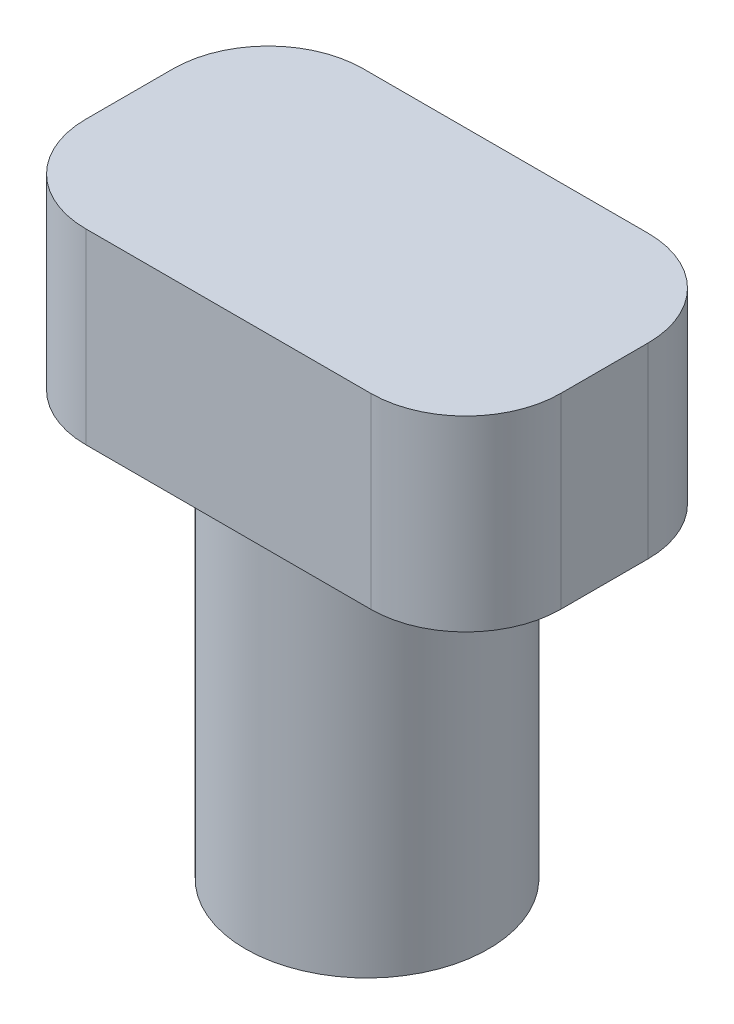
from build123d import *

# Parameters (mm, degrees)
SKETCH1_R           = 3.25
BOSS_EXTRUDE1_DEPTH = 10
SKETCH2_R           = 1.75
CUT_EXTRUDE1_DEPTH  = 2.5
SKETCH3_W           = 12.7
SKETCH3_H           = 7.4168
BOSS_EXTRUDE2_DEPTH = 5
FILLET1_R           = 2.54


with BuildPart() as part:
    # Sketch1 → Boss-Extrude1 (new body)
    with BuildSketch(Plane(origin=(0, 0, 0), x_dir=(1, 0, 0), z_dir=(0, 1, 0))):
        Circle(SKETCH1_R)
    extrude(amount=BOSS_EXTRUDE1_DEPTH)

    # Sketch2 → Cut-Extrude1 (cut)
    with BuildSketch(Plane.XZ):
        Circle(SKETCH2_R)
    extrude(amount=-CUT_EXTRUDE1_DEPTH, mode=Mode.SUBTRACT)

    # Sketch3 → Boss-Extrude2 (add)
    with BuildSketch(Plane(origin=(0, 10, 0), x_dir=(1, 0, 0), z_dir=(0, 1, 0))):
        Rectangle(SKETCH3_W, SKETCH3_H)
    extrude(amount=BOSS_EXTRUDE2_DEPTH)

    # Fillet1
    fillet1_edges = [part.edges().sort_by_distance(p)[0] for p in [
        (6.35, 12.5, 3.7084),
        (6.35, 12.5, -3.7084),
        (-6.35, 12.5, -3.7084),
        (-6.35, 12.5, 3.7084),
    ]]
    fillet(fillet1_edges, radius=FILLET1_R)


solid = part.part
